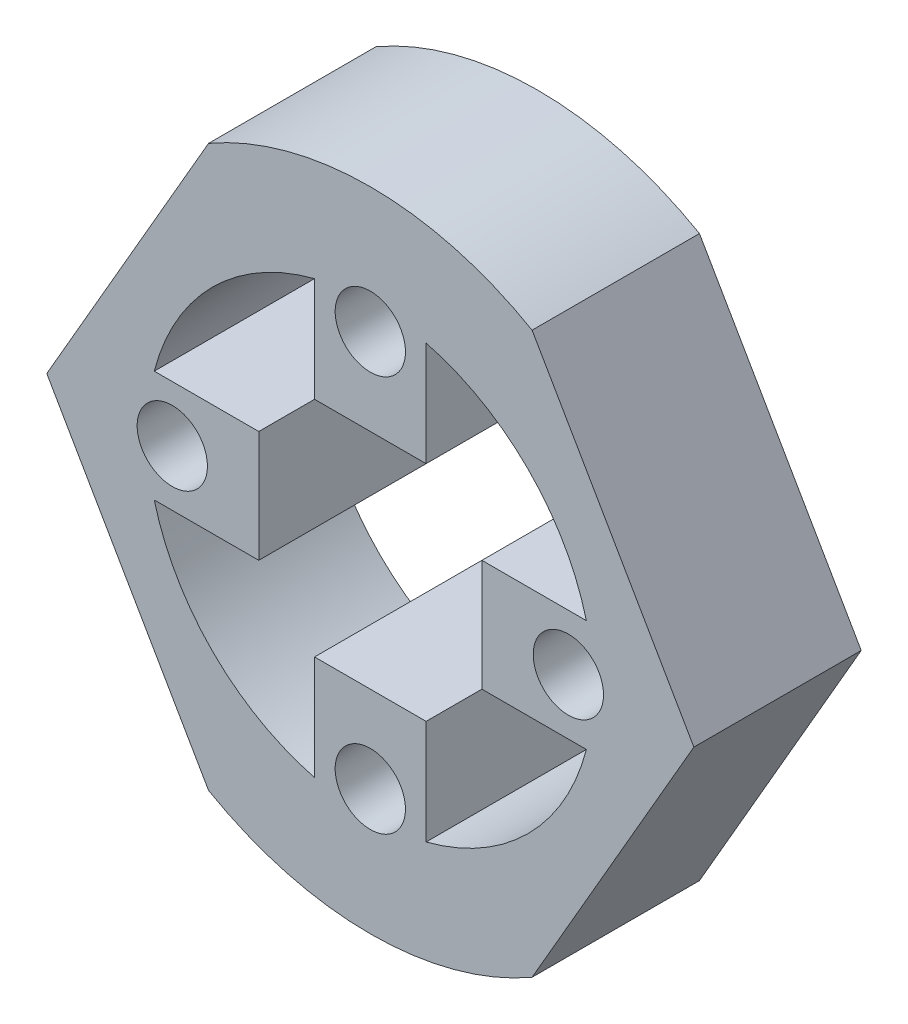
from build123d import *

# Parameters (mm, degrees)
SKETCH6_R                 = 29
SKETCH6_R_2               = 20
INNER_RING_DEPTH          = 15
MOTOR_CONNECTOR_CUT_DEPTH = 15
CUT_EXTRUDE1_DEPTH        = 16
CUT_EXTRUDE1_DEPTH_BACK   = 27
SKETCH10_R                = 3.15
CUT_EXTRUDE2_DEPTH        = 55
CUT_EXTRUDE2_DEPTH_BACK   = 70


with BuildPart() as part:
    # Sketch6 → Inner Ring (new body)
    with BuildSketch(Plane.XY):
        Circle(SKETCH6_R)
        Circle(SKETCH6_R_2, mode=Mode.SUBTRACT)
    extrude(amount=-INNER_RING_DEPTH)

    # Sketch7 → Motor Connector Cut (add)
    with BuildSketch(Plane.XY):
        with BuildLine():
            ThreePointArc((20, 0), (19.840593925, 2.52008585), (19.364916731, 5))
            Line((19.364916731, 5), (9.999996731, 5))
            Line((9.999996731, 5), (9.999996731, -5))
            Line((9.999996731, -5), (19.364916731, -5))
            ThreePointArc((19.364916731, -5), (19.840593925, -2.52008585), (20, 0))
        make_face()
        with BuildLine():
            ThreePointArc((5, 19.364916731), (0, 20), (-5, 19.364916731))
            Line((-5, 19.364916731), (-5, 9.999996731))
            Line((-5, 9.999996731), (5, 9.999996731))
            Line((5, 9.999996731), (5, 19.364916731))
        make_face()
        with BuildLine():
            Line((-9.999996731, -5), (-9.999996731, 5))
            Line((-9.999996731, 5), (-19.364916731, 5))
            ThreePointArc((-19.364916731, 5), (-20, 0), (-19.364916731, -5))
            Line((-19.364916731, -5), (-9.999996731, -5))
        make_face()
        with BuildLine():
            Line((-5, -9.999996731), (-5, -19.364916731))
            ThreePointArc((-5, -19.364916731), (0, -20), (5, -19.364916731))
            Line((5, -19.364916731), (5, -9.999996731))
            Line((5, -9.999996731), (-5, -9.999996731))
        make_face()
    extrude(amount=-MOTOR_CONNECTOR_CUT_DEPTH)

    # Sketch9 → Cut-Extrude1 (cut, two sides)
    with BuildSketch(Plane(origin=(0, 0, -15), x_dir=(-1, 0, 0), z_dir=(0, 0, -1))) as cut_extrude1_sk:
        with BuildLine():
            Line((14.5, 25.11473671), (29, 0))
            ThreePointArc((29, 0), (25.11473671, 14.5), (14.5, 25.11473671))
        make_face()
        with BuildLine():
            Line((-29, 0), (-14.5, 25.11473671))
            ThreePointArc((-14.5, 25.11473671), (-25.11473671, 14.5), (-29, 0))
        make_face()
        with BuildLine():
            ThreePointArc((-29, 0), (-25.11473671, -14.5), (-14.5, -25.11473671))
            Line((-14.5, -25.11473671), (-29, 0))
        make_face()
        with BuildLine():
            ThreePointArc((14.5, -25.11473671), (25.11473671, -14.5), (29, 0))
            Line((29, 0), (14.5, -25.11473671))
        make_face()
    extrude(amount=CUT_EXTRUDE1_DEPTH, mode=Mode.SUBTRACT)
    extrude(cut_extrude1_sk.sketch, amount=-CUT_EXTRUDE1_DEPTH_BACK, mode=Mode.SUBTRACT)

    # Sketch10 → Cut-Extrude2 (cut, two sides)
    with BuildSketch(Plane(origin=(0, 0, -15), x_dir=(-1, 0, 0), z_dir=(0, 0, -1))) as cut_extrude2_sk:
        with Locations((-17.75, 0)):
            Circle(SKETCH10_R)
        with Locations((0, 17.75)):
            Circle(SKETCH10_R)
        with Locations((17.75, 0)):
            Circle(SKETCH10_R)
        with Locations((0, -17.75)):
            Circle(SKETCH10_R)
    extrude(amount=CUT_EXTRUDE2_DEPTH, mode=Mode.SUBTRACT)
    extrude(cut_extrude2_sk.sketch, amount=-CUT_EXTRUDE2_DEPTH_BACK, mode=Mode.SUBTRACT)


solid = part.part
